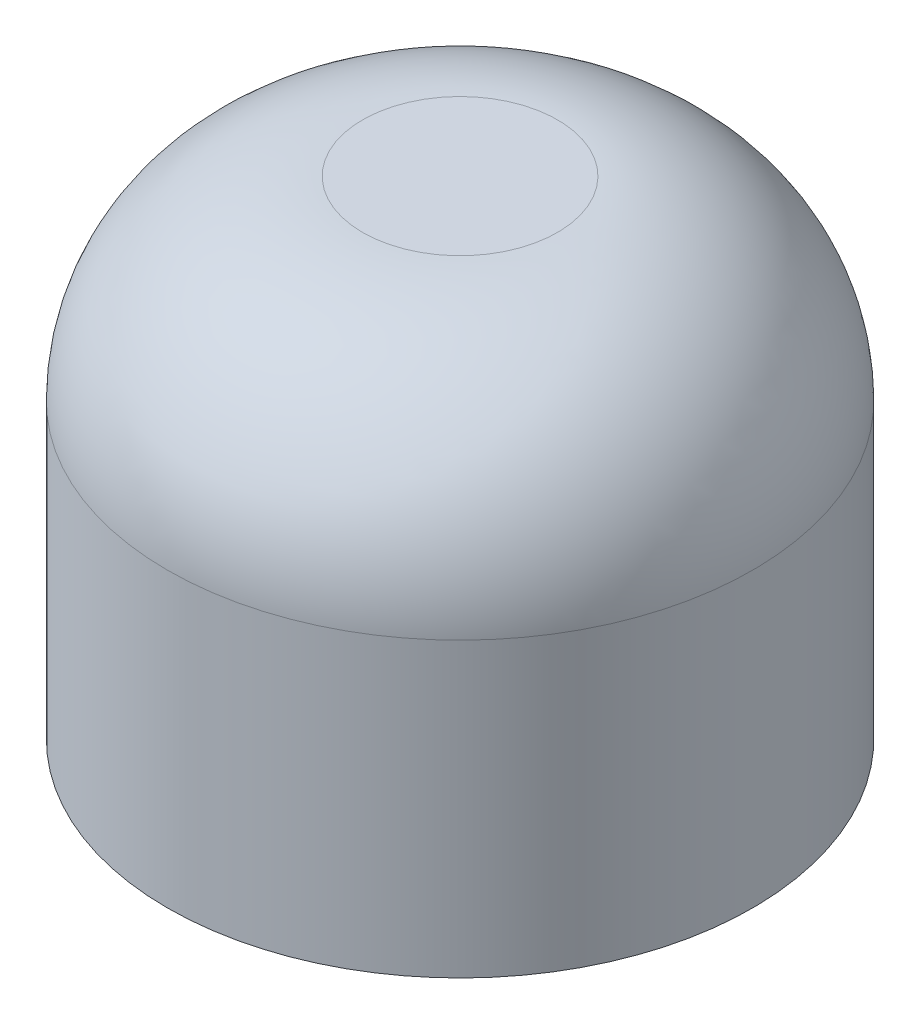
from build123d import *

# Parameters (mm, degrees)
SKETCH_1_R      = 3
EXTRUDE_1_DEPTH = 5
FILLET_2_R      = 2


with BuildPart() as part:
    # Эскиз1 → Бобышка-Вытянуть1 (new body)
    with BuildSketch(Plane(origin=(0, 0, 0), x_dir=(1, 0, 0), z_dir=(0, 1, 0))):
        Circle(SKETCH_1_R)
    extrude(amount=EXTRUDE_1_DEPTH)

    # Скругление2
    fillet_2_edges = [part.edges().sort_by_distance(p)[0] for p in [
        (-3, 5, 0),
    ]]
    fillet(fillet_2_edges, radius=FILLET_2_R)


solid = part.part
